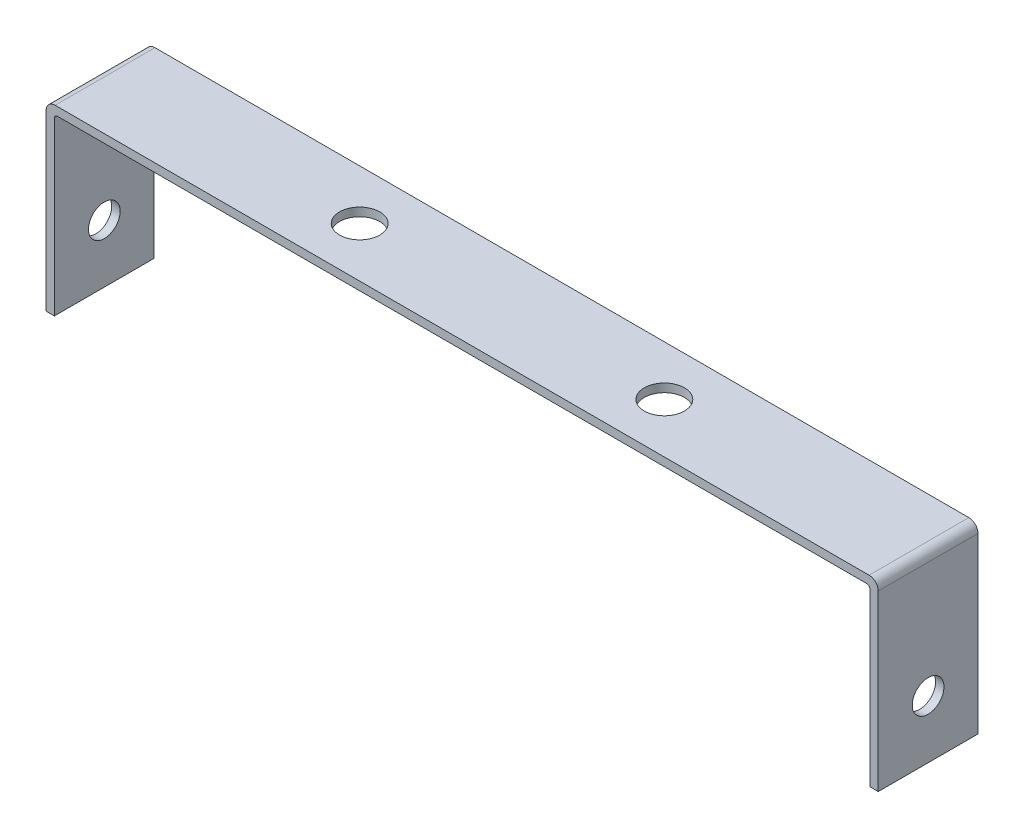
from build123d import *

# Parameters (mm, degrees)
SKETCH1_W           = 133.8
SKETCH1_H           = 16.37
SKETCH1_R           = 3.3
BOSS_EXTRUDE1_DEPTH = 1.38
SKETCH2_W           = 1.38
SKETCH2_H           = 16.37
BOSS_EXTRUDE2_DEPTH = 30
FILLET1_R           = 1.5
FILLET2_R           = 0.5
SKETCH3_R           = 2.6
CUT_EXTRUDE1_DEPTH  = 137.56


with BuildPart() as part:
    # Sketch1 → Boss-Extrude1 (new body)
    with BuildSketch(Plane(origin=(0, 0, 0), x_dir=(1, 0, 0), z_dir=(0, 1, 0))):
        with Locations((-5.141278074, 20.650419702)):
            Rectangle(SKETCH1_W, SKETCH1_H)
        with Locations((-30.141278074, 20.650419702)):
            Circle(SKETCH1_R, mode=Mode.SUBTRACT)
        with Locations((19.858721926, 20.650419702)):
            Circle(SKETCH1_R, mode=Mode.SUBTRACT)
    extrude(amount=BOSS_EXTRUDE1_DEPTH)

    # Sketch2 → Boss-Extrude2 (add)
    with BuildSketch(Plane(origin=(0, 1.38, 0), x_dir=(1, 0, 0), z_dir=(0, 1, 0))):
        with Locations((-72.731278074, 20.650419702)):
            Rectangle(SKETCH2_W, SKETCH2_H)
        with Locations((62.448721926, 20.650419702)):
            Rectangle(SKETCH2_W, SKETCH2_H)
    extrude(amount=-BOSS_EXTRUDE2_DEPTH)

    # Fillet1
    fillet1_edges = [part.edges().sort_by_distance(p)[0] for p in [
        (-73.421278074, 1.38, -20.650419702),
        (63.138721926, 1.38, -20.650419702),
    ]]
    fillet(fillet1_edges, radius=FILLET1_R)

    # Fillet2
    fillet2_edges = [part.edges().sort_by_distance(p)[0] for p in [
        (-72.041278074, 0, -20.650419702),
        (61.758721926, 0, -20.650419702),
    ]]
    fillet(fillet2_edges, radius=FILLET2_R)

    # Sketch3 → Cut-Extrude1 (cut, through all)
    with BuildSketch(Plane.ZY.offset(73.421278074)):
        with Locations((-20.650419702, -19.12)):
            Circle(SKETCH3_R)
    extrude(amount=-CUT_EXTRUDE1_DEPTH, mode=Mode.SUBTRACT)


solid = part.part
